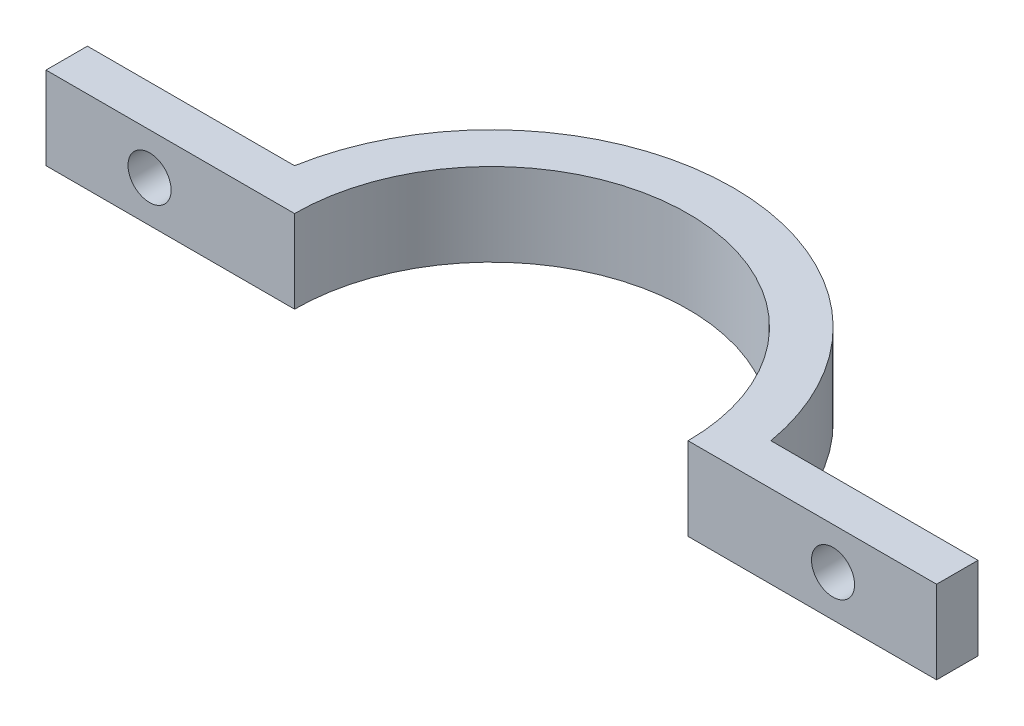
from build123d import *

# Parameters (mm, degrees)
BOSS_EXTRUDE1_DEPTH = 6.35
SKETCH2_R           = 1.651
CUT_EXTRUDE1_DEPTH  = 6.35


with BuildPart() as part:
    # Sketch1 → Boss-Extrude1 (new body)
    with BuildSketch(Plane(origin=(0, 0, 0), x_dir=(1, 0, 0), z_dir=(0, 1, 0))):
        with BuildLine():
            Line((-15.08125, 0), (-34.13125, 0))
            Line((-34.13125, 0), (-34.13125, 3.175))
            Line((-34.13125, 3.175), (-18.25625, 3.175))
            ThreePointArc((-18.25625, 3.175), (0, 18.530280329), (18.25625, 3.175))
            Line((18.25625, 3.175), (34.13125, 3.175))
            Line((34.13125, 3.175), (34.13125, 0))
            Line((34.13125, 0), (15.08125, 0))
            ThreePointArc((15.08125, 0), (0, 15.08125), (-15.08125, 0))
        make_face()
    extrude(amount=BOSS_EXTRUDE1_DEPTH)

    # Sketch2 → Cut-Extrude1 (cut)
    with BuildSketch(Plane(origin=(0, 0, -3.175), x_dir=(-1, 0, 0), z_dir=(0, 0, -1))):
        with Locations((26.19375, 3.175)):
            Circle(SKETCH2_R)
    cut_extrude1 = extrude(amount=-CUT_EXTRUDE1_DEPTH, mode=Mode.SUBTRACT)

    # Mirror1: Cut-Extrude1 across plane
    add(cut_extrude1.mirror(Plane(origin=(0, 0, 0), x_dir=(0, 0, 1), z_dir=(1, 0, 0))), mode=Mode.SUBTRACT)


solid = part.part
